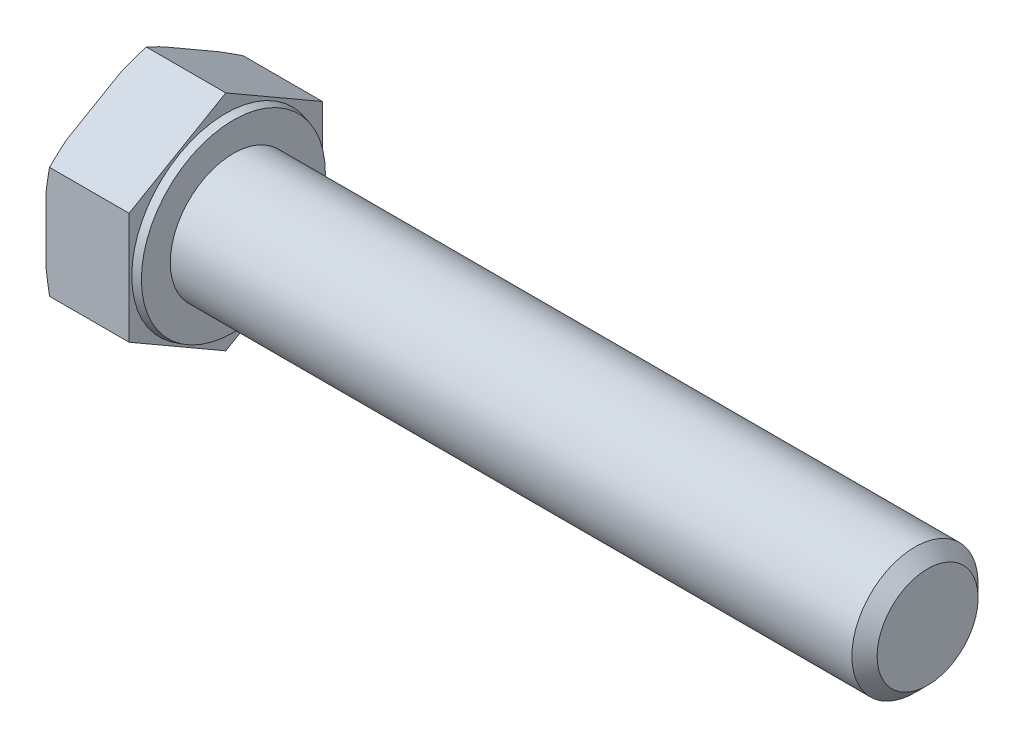
from build123d import *

# Parameters (mm, degrees)
SKETCH_2_OUTSIDE_W  = 33.106
SKETCH_2_OUTSIDE_H  = 33.106
CUT_EXTRUDE_1_DEPTH = 64.42710304
CHAMFER_1_SIZE      = 1


with BuildPart() as part:
    # Эскиз1 → Повернуть1 (revolve)
    with BuildSketch(Plane.XY, mode=Mode.PRIVATE) as revolve_1_sk:
        Polygon((-6.58, 0), (-6.58, 8.85), (0, 8.85), (0, 7.448974596), (0.6, 7.288205081), (0.6, 5), (55.6, 5), (55.6, 0), align=None)
    revolve(revolve_1_sk.sketch.rotate(Axis((-1000, 0, 0), (1, 0, 0)), 90), axis=Axis((-1000, 0, 0), (1, 0, 0)))

    # Эскиз2 outside → Вырез-Вытянуть1 (cut, through all)
    with BuildSketch(Plane.ZY.offset(6.58)):
        Rectangle(SKETCH_2_OUTSIDE_W, SKETCH_2_OUTSIDE_H)
        Polygon((0, -8.85), (7.664324823, -4.425), (7.664324823, 4.425), (0, 8.85), (-7.664324823, 4.425), (-7.664324823, -4.425), align=None, mode=Mode.SUBTRACT)
    extrude(amount=-CUT_EXTRUDE_1_DEPTH, mode=Mode.SUBTRACT)

    # Эскиз4 → Вырез-Повернуть1 (revolve, cut)
    with BuildSketch(Plane.XY):
        Polygon((-6.58, 8.075), (-6.297923068, 8.85), (-6.58, 8.85), align=None)
    revolve(axis=Axis((-1000, 0, 0), (1, 0, 0)), mode=Mode.SUBTRACT)

    # Фаска1
    chamfer_1_edges = [part.edges().sort_by_distance(p)[0] for p in [
        (55.6, 0, -5),
    ]]
    chamfer(chamfer_1_edges, length=CHAMFER_1_SIZE)


solid = part.part
